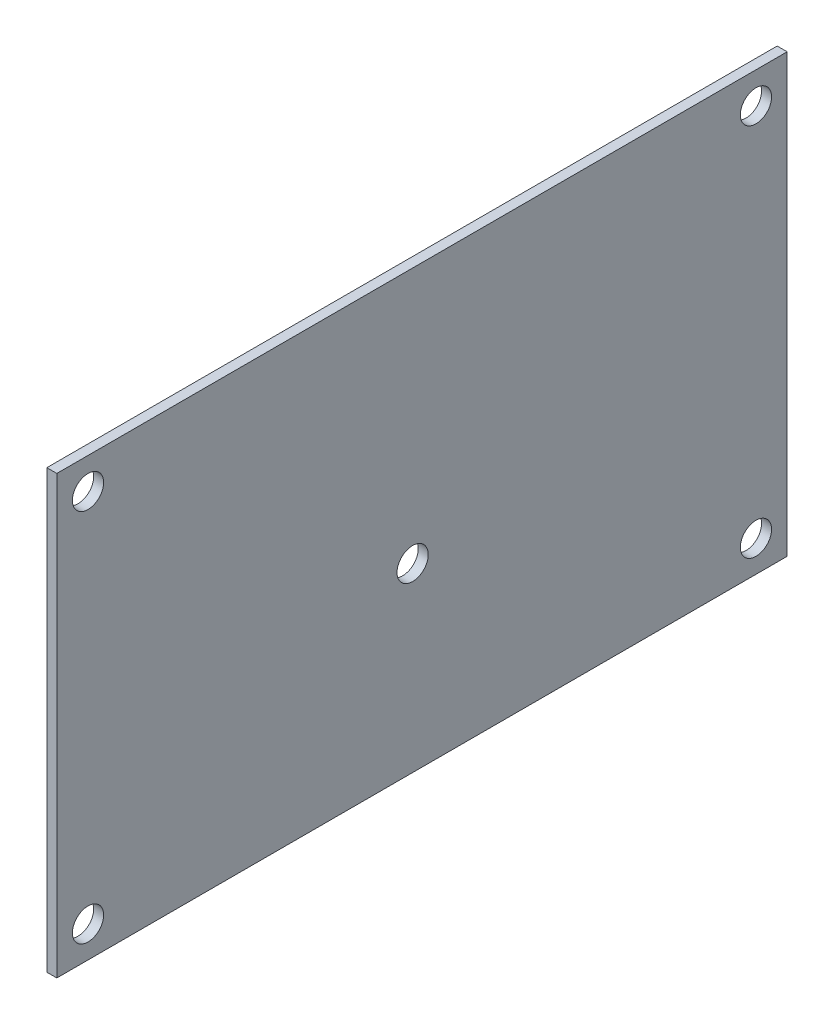
from build123d import *

# Parameters (mm, degrees)
SKETCH1_W           = 117
SKETCH1_H           = 70
BOSS_EXTRUDE1_DEPTH = 1.6
SKETCH2_R           = 2.5
CUT_EXTRUDE1_DEPTH  = 2.6


with BuildPart() as part:
    # Sketch1 → Boss-Extrude1 (new body)
    with BuildSketch(Plane(origin=(0, 0, 0), x_dir=(0, 0, -1), z_dir=(1, 0, 0))):
        with Locations((58.5, 35)):
            Rectangle(SKETCH1_W, SKETCH1_H)
    extrude(amount=BOSS_EXTRUDE1_DEPTH)

    # Sketch2 → Cut-Extrude1 (cut, through all)
    with BuildSketch(Plane(origin=(1.6, 0, 0), x_dir=(0, 0, -1), z_dir=(1, 0, 0))):
        with Locations((5, 65)):
            Circle(SKETCH2_R)
        with Locations((5, 5)):
            Circle(SKETCH2_R)
        with Locations((112, 5)):
            Circle(SKETCH2_R)
        with Locations((112, 65)):
            Circle(SKETCH2_R)
        with Locations((57, 29)):
            Circle(SKETCH2_R)
    extrude(amount=-CUT_EXTRUDE1_DEPTH, mode=Mode.SUBTRACT)


solid = part.part
